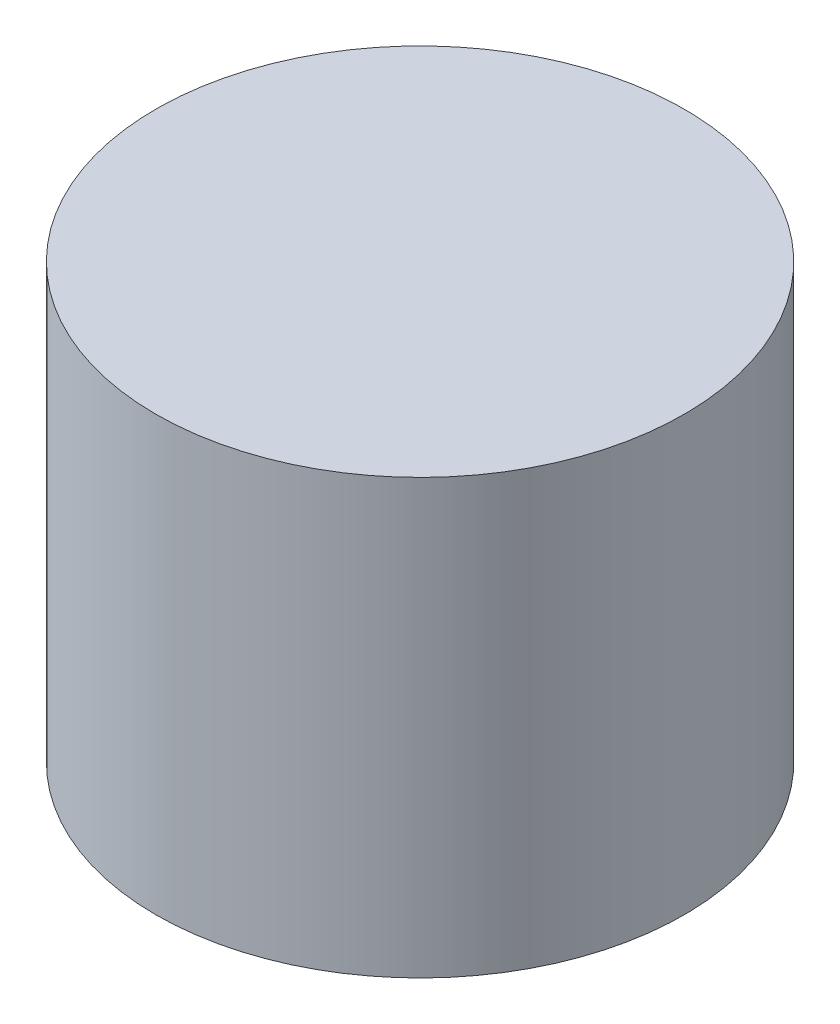
from build123d import *

# Parameters (mm, degrees)
SKETCH1_R           = 32
BOSS_EXTRUDE1_DEPTH = 26.25


with BuildPart() as part:
    # Sketch1 → Boss-Extrude1 (new body, symmetric)
    with BuildSketch(Plane(origin=(0, 0, 0), x_dir=(1, 0, 0), z_dir=(0, 1, 0))):
        Circle(SKETCH1_R)
    extrude(amount=BOSS_EXTRUDE1_DEPTH, both=True)


solid = part.part
